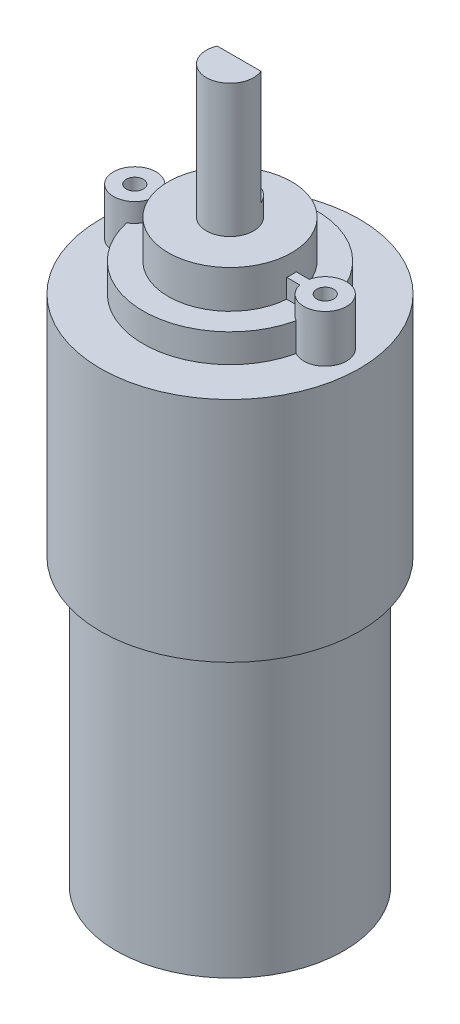
from build123d import *

# Parameters (mm, degrees)
CROQUIS1_W              = 2.5
CROQUIS1_H              = 14
CORTAR_EXTRUIR1_DEPTH   = 12
CROQUIS4_R              = 2.25
CROQUIS4_R_2            = 0.9
CROQUIS4_W              = 18
CROQUIS4_H              = 1
SALIENTE_EXTRUIR1_DEPTH = 5


with BuildPart() as part:
    # Croquis1 → Revolución1 (revolve)
    with BuildSketch(Plane.XY):
        with Locations((-1.25, 37.5)):
            Rectangle(CROQUIS1_W, CROQUIS1_H)
        Polygon((-12, -30.5), (0, -30.5), (0, 30.5), (-6.5, 30.5), (-6.5, 26.5), (-9.15, 26.5), (-9.15, 23.5), (-13.65, 23.5), (-13.65, -0.5), (-12, -0.5), align=None)
    revolve(axis=Axis((0, 65.687156563, 0), (0, -1, 0)))

    # Croquis2 → Cortar-Extruir1 (cut)
    with BuildSketch(Plane(origin=(0, 44.5, 0), x_dir=(1, 0, 0), z_dir=(0, 1, 0))):
        Polygon((-55.580517034, 0.96), (-2.308332732, 0.96), (2.308332732, 0.96), (55.580517034, 0.96), (55.580517034, 107.504368605), (-55.580517034, 107.504368605), align=None)
    extrude(amount=-CORTAR_EXTRUIR1_DEPTH, mode=Mode.SUBTRACT)

    # Croquis4 → Saliente-Extruir1 (add)
    with BuildSketch(Plane(origin=(0, 23.5, 0), x_dir=(1, 0, 0), z_dir=(0, 1, 0))):
        with Locations((-10.04, 0)):
            Circle(CROQUIS4_R)
        with Locations((-10.04, 0)):
            Circle(CROQUIS4_R_2, mode=Mode.SUBTRACT)
        with Locations((10.04, 0)):
            Circle(CROQUIS4_R)
        with Locations((10.04, 0)):
            Circle(CROQUIS4_R_2, mode=Mode.SUBTRACT)
        Rectangle(CROQUIS4_W, CROQUIS4_H)
    extrude(amount=SALIENTE_EXTRUIR1_DEPTH)


solid = part.part
